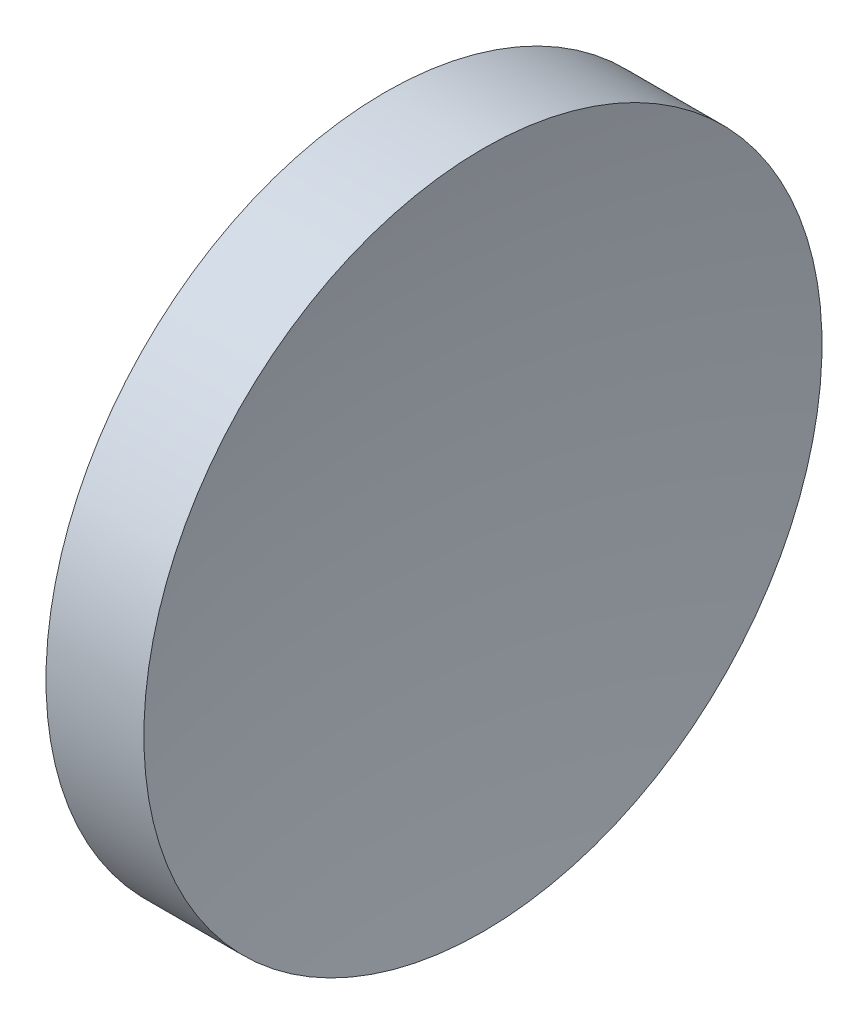
from build123d import *


with BuildPart() as part:
    # 草图1 → 旋转1 (revolve)
    with BuildSketch(Plane.XY, mode=Mode.PRIVATE) as revolve_1_sk:
        with BuildLine():
            Line((114.986171093, 65.157451827), (114.986171093, 82.157451827))
            Line((114.986171093, 82.157451827), (119.893829221, 82.157451827))
            ThreePointArc((119.893829221, 82.157451827), (118.65156604, 73.697765499), (118.236171093, 65.157451827))
            Line((118.236171093, 65.157451827), (114.986171093, 65.157451827))
        make_face()
    revolve(revolve_1_sk.sketch.rotate(Axis((110.014789249, 65.157451827, 0), (1, 0, 0)), 180), axis=Axis((110.014789249, 65.157451827, 0), (1, 0, 0)))  # turned: the seam where the file's is


solid = part.part
